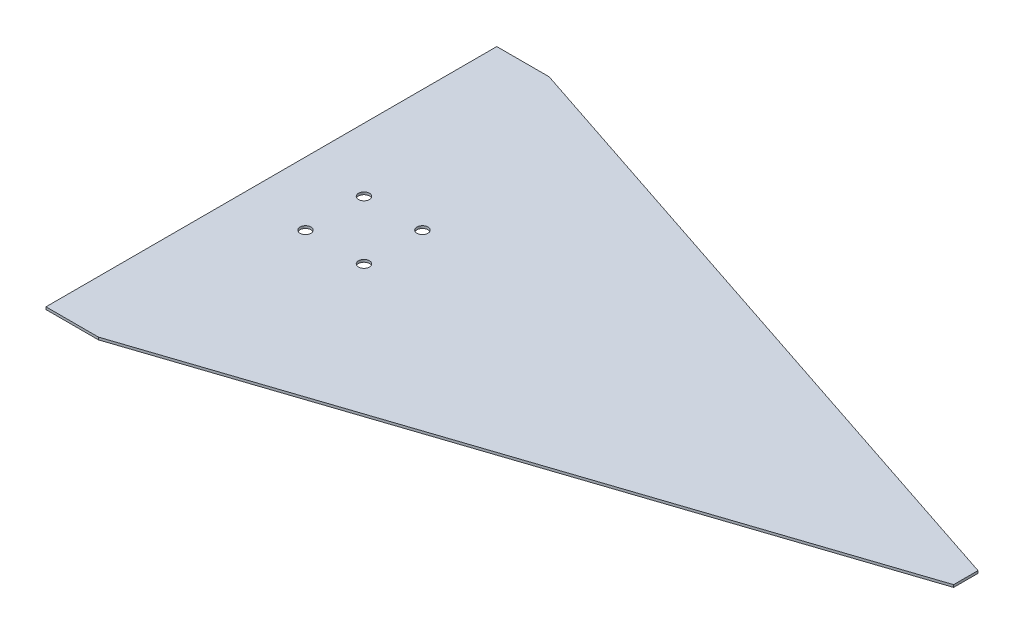
from build123d import *

# Parameters (mm, degrees)
BOSS_EXTRUDE1_DEPTH = 1
SKETCH3_R           = 2.25
CUT_EXTRUDE1_DEPTH  = 1


with BuildPart() as part:
    # Sketch2 → Boss-Extrude1 (new body)
    with BuildSketch(Plane(origin=(0, 0, 0), x_dir=(1, 0, 0), z_dir=(0, 1, 0))):
        Polygon((-142.5, -92.5), (-121, -92.5), (142.5, -5), (142.5, 5), (-121, 92.5), (-142.5, 92.5), align=None)
    extrude(amount=BOSS_EXTRUDE1_DEPTH)

    # Sketch3 → Cut-Extrude1 (cut)
    with BuildSketch(Plane(origin=(0, 1, 0), x_dir=(1, 0, 0), z_dir=(0, 1, 0))):
        with Locations((-116.5, 12)):
            Circle(SKETCH3_R)
        with Locations((-92.5, 12)):
            Circle(SKETCH3_R)
        with Locations((-116.5, -12)):
            Circle(SKETCH3_R)
        with Locations((-92.5, -12)):
            Circle(SKETCH3_R)
    extrude(amount=-CUT_EXTRUDE1_DEPTH, mode=Mode.SUBTRACT)


solid = part.part
